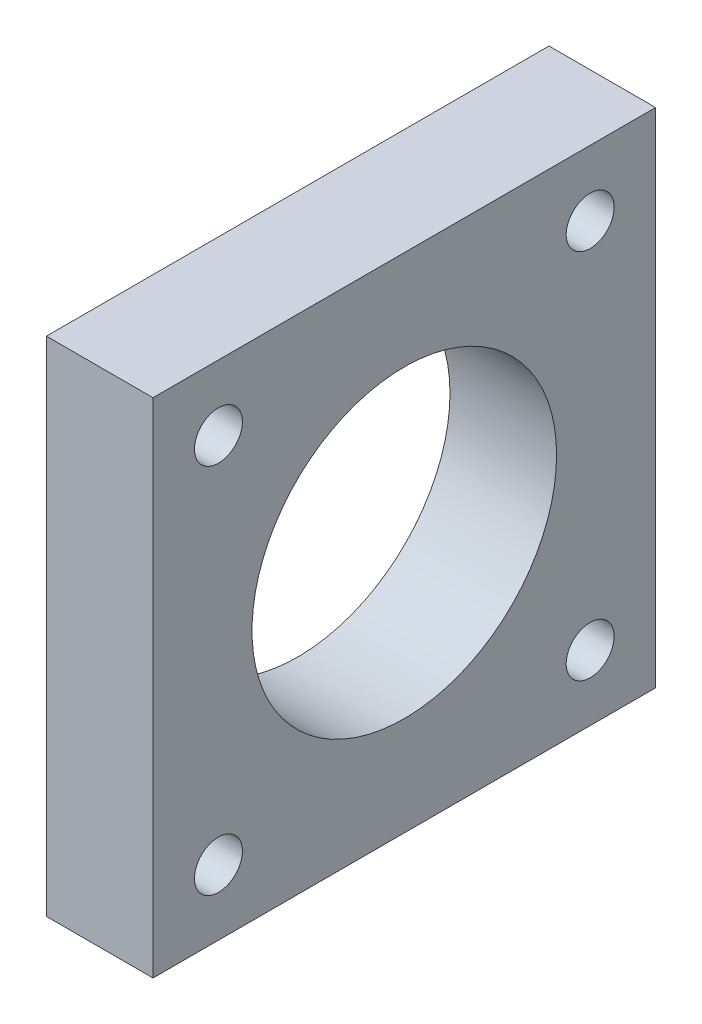
from build123d import *

# Parameters (mm, degrees)
SKETCH37_W           = 41.91
SKETCH37_H           = 41.91
SKETCH37_R           = 12.7
SKETCH37_R_2         = 2
BOSS_EXTRUDE27_DEPTH = 8.89
SKETCH37_9_R         = 2.999999969
CUT_EXTRUDE1_DEPTH   = 4.000000128


with BuildPart() as part:
    # Sketch37 → Boss-Extrude27 (new body)
    with BuildSketch(Plane(origin=(0, 0, 0), x_dir=(0, 0, -1), z_dir=(1, 0, 0))):
        Rectangle(SKETCH37_W, SKETCH37_H)
        Circle(SKETCH37_R, mode=Mode.SUBTRACT)
        with Locations((-15.5, -15.5)):
            Circle(SKETCH37_R_2, mode=Mode.SUBTRACT)
        with Locations((15.5, -15.5)):
            Circle(SKETCH37_R_2, mode=Mode.SUBTRACT)
        with Locations((-15.5, 15.5)):
            Circle(SKETCH37_R_2, mode=Mode.SUBTRACT)
        with Locations((15.5, 15.5)):
            Circle(SKETCH37_R_2, mode=Mode.SUBTRACT)
    extrude(amount=BOSS_EXTRUDE27_DEPTH)

    # Sketch37_9 → Cut-Extrude1 (cut)
    with BuildSketch(Plane(origin=(0, 0, 0), x_dir=(0, 0, -1), z_dir=(1, 0, 0))):
        with Locations((15.5, 15.5)):
            Circle(SKETCH37_9_R)
        with Locations((-15.5, 15.5)):
            Circle(SKETCH37_9_R)
        with Locations((-15.5, -15.5)):
            Circle(SKETCH37_9_R)
        with Locations((15.5, -15.5)):
            Circle(SKETCH37_9_R)
    extrude(amount=CUT_EXTRUDE1_DEPTH, mode=Mode.SUBTRACT)


solid = part.part
